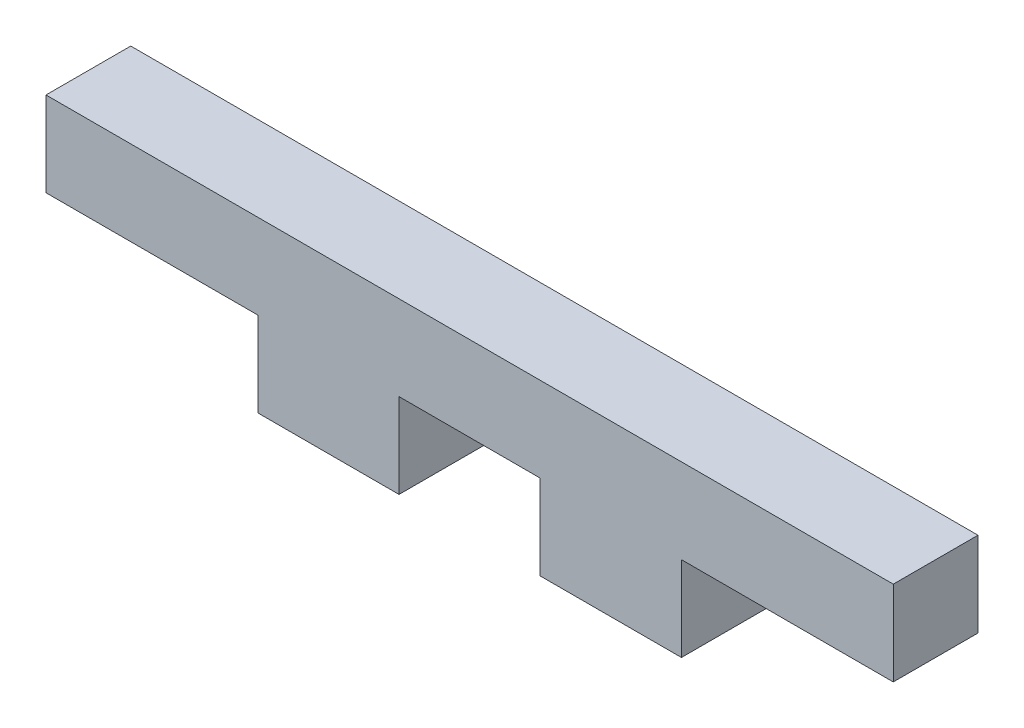
from build123d import *

# Parameters (mm, degrees)
BOSS_EXTRU_1_DEPTH = 3


with BuildPart() as part:
    # Esquisse1 → Boss.-Extru.1 (new body)
    with BuildSketch(Plane.XY):
        Polygon((18.990106642, -2.899569673), (18.990106642, 0.100430327), (26.490106642, 0.100430327), (26.490106642, 3.100430327), (-3.509893358, 3.100430327), (-3.509893358, 0.100430327), (3.990106642, 0.100430327), (3.990106642, -2.899569673), (8.990106642, -2.899569673), (8.990106642, 0.100430327), (13.990106642, 0.100430327), (13.990106642, -2.899569673), align=None)
    extrude(amount=BOSS_EXTRU_1_DEPTH)


solid = part.part
